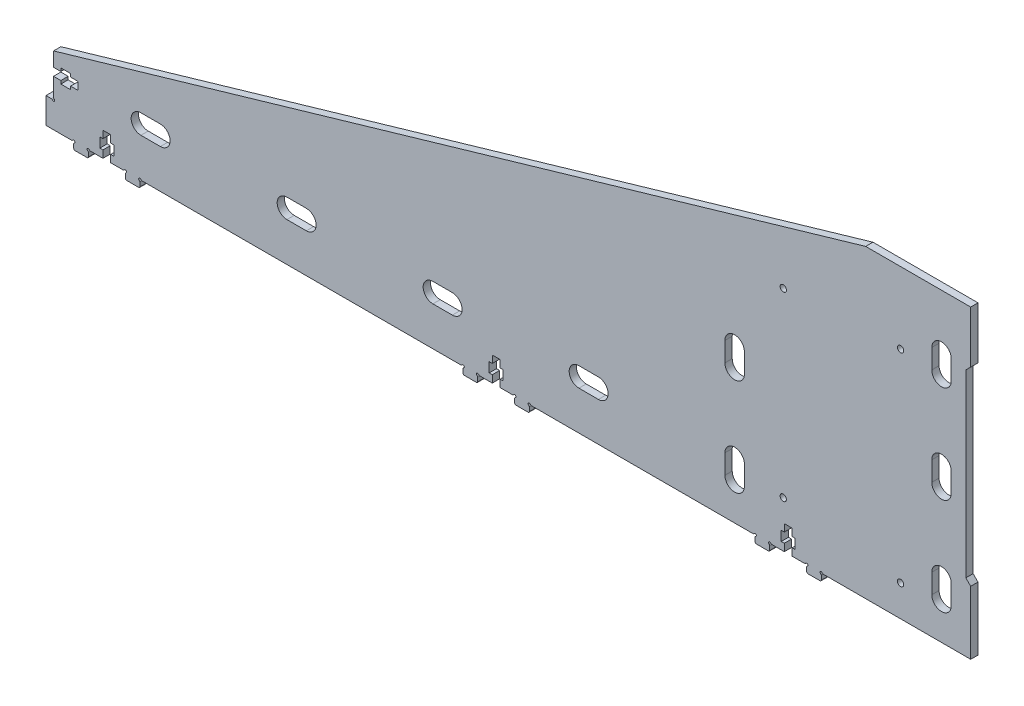
from build123d import *

# Parameters (mm, degrees)
MODEL_R                 = 1.3
SALIENTE_EXTRUIR1_DEPTH = 3


with BuildPart() as part:
    # Model → Saliente-Extruir1 (new body)
    with BuildSketch(Plane.XY):
        with BuildLine():
            Line((387.474128322, 263.996311498), (448.008092322, 263.996308498))
            Line((448.008092322, 263.996308498), (448.008092322, 289.996308498))
            Line((448.008092322, 289.996308498), (446.008092322, 291.996308498))
            Line((446.008092322, 291.996308498), (446.008092322, 365.996306498))
            Line((446.008092322, 365.996306498), (448.008092322, 367.996310498))
            Line((448.008092322, 367.996310498), (448.008092322, 389.371331818))
            Line((448.008092322, 389.371331818), (404.844163308, 389.371331818))
            Line((404.844163308, 389.371331818), (403.197581262, 388.89131343))
            Line((403.197581262, 388.89131343), (81.108137322, 294.994470498))
            Line((81.108137322, 294.994470498), (71.108137322, 292.07922926))
            Line((71.108137322, 292.07922926), (71.108137322, 286.246313498))
            Line((71.108137322, 286.246313498), (74.108109322, 286.246313498))
            Line((74.108109322, 286.246313498), (74.108109322, 287.521307498))
            Line((74.108109322, 287.521307498), (78.108137322, 287.521307498))
            Line((78.108137322, 287.521307498), (78.108137322, 286.246313498))
            Line((78.108137322, 286.246313498), (81.108137322, 286.246313498))
            Line((81.108137322, 286.246313498), (81.108137322, 283.046302498))
            Line((81.108137322, 283.046302498), (78.108137322, 283.046302498))
            Line((78.108137322, 283.046302498), (78.108137322, 281.771307498))
            Line((78.108137322, 281.771307498), (74.108109322, 281.771307498))
            Line((74.108109322, 281.771307498), (74.108109322, 283.046302498))
            Line((74.108109322, 283.046302498), (71.108137322, 283.046302498))
            Line((71.108137322, 283.046302498), (71.108140322, 275.512331498))
            ThreePointArc((71.108140322, 275.512331498), (71.175127106, 275.26233206), (71.358138826, 275.079319332))
            ThreePointArc((71.358138826, 275.079319332), (71.461690809, 274.292753249), (70.675125024, 274.396307498))
            ThreePointArc((70.675125024, 274.396307498), (70.492112322, 274.5793202), (70.242112322, 274.646307498))
            Line((70.242112322, 274.646307498), (68.008065322, 274.646307498))
            Line((68.008065322, 274.646307498), (68.008065322, 263.996308498))
            Line((68.008065322, 263.996308498), (78.542065322, 263.996308498))
            ThreePointArc((78.542065322, 263.996308498), (78.79206566, 264.063295647), (78.97507862, 264.246308498))
            ThreePointArc((78.97507862, 264.246308498), (79.7616439, 264.349861925), (79.658092826, 263.563296336))
            ThreePointArc((79.658092826, 263.563296336), (79.475081188, 263.38028375), (79.408094322, 263.130284498))
            Line((79.408094322, 263.130284498), (79.408094322, 261.496256498))
            ThreePointArc((79.408094322, 261.496256498), (79.554540932, 261.142703108), (79.908094322, 260.996256498))
            Line((79.908094322, 260.996256498), (84.908091322, 260.996256498))
            ThreePointArc((84.908091322, 260.996256498), (85.261644713, 261.142703108), (85.408091322, 261.496256498))
            Line((85.408091322, 261.496256498), (85.408088322, 263.130282498))
            ThreePointArc((85.408088322, 263.130282498), (85.341101173, 263.380282836), (85.158088322, 263.563295796))
            ThreePointArc((85.158088322, 263.563295796), (85.054534895, 264.349861076), (85.841100484, 264.246310002))
            ThreePointArc((85.841100484, 264.246310002), (86.02411307, 264.063298364), (86.274112322, 263.996311498))
            Line((86.274112322, 263.996311498), (91.408077322, 263.996308498))
            Line((91.408077322, 263.996308498), (91.408077322, 266.996280498))
            Line((91.408077322, 266.996280498), (90.133082322, 266.996280498))
            Line((90.133082322, 266.996280498), (90.133082322, 270.996308498))
            Line((90.133082322, 270.996308498), (91.408077322, 270.996308498))
            Line((91.408077322, 270.996308498), (91.408077322, 273.996308498))
            Line((91.408077322, 273.996308498), (94.608088322, 273.996308498))
            Line((94.608088322, 273.996308498), (94.608088322, 270.996308498))
            Line((94.608088322, 270.996308498), (95.883082322, 270.996308498))
            Line((95.883082322, 270.996308498), (95.883082322, 266.996280498))
            Line((95.883082322, 266.996280498), (94.608088322, 266.996280498))
            Line((94.608088322, 266.996280498), (94.608088322, 263.996308498))
            Line((94.608088322, 263.996308498), (99.742082322, 263.996308498))
            ThreePointArc((99.742082322, 263.996308498), (99.992082093, 264.063295897), (100.17509462, 264.246308498))
            ThreePointArc((100.17509462, 264.246308498), (100.9616599, 264.349861925), (100.858108826, 263.563296336))
            ThreePointArc((100.858108826, 263.563296336), (100.675097188, 263.38028375), (100.608110322, 263.130284498))
            Line((100.608110322, 263.130284498), (100.608110322, 261.496256498))
            ThreePointArc((100.608110322, 261.496256498), (100.754556932, 261.142703108), (101.108110322, 260.996256498))
            Line((101.108110322, 260.996256498), (106.108107322, 260.996256498))
            ThreePointArc((106.108107322, 260.996256498), (106.461660713, 261.142703108), (106.608107322, 261.496256498))
            Line((106.608107322, 261.496256498), (106.608104322, 263.130282498))
            ThreePointArc((106.608104322, 263.130282498), (106.541117173, 263.380282836), (106.358104322, 263.563295796))
            ThreePointArc((106.358104322, 263.563295796), (106.254550895, 264.349861076), (107.041116484, 264.246310002))
            ThreePointArc((107.041116484, 264.246310002), (107.22412907, 264.063298364), (107.474128322, 263.996311498))
            Line((107.474128322, 263.996311498), (238.540330274, 263.996311498))
            Line((238.540330274, 263.996311498), (238.542062322, 263.996311498))
            ThreePointArc((238.542062322, 263.996311498), (238.792061575, 264.063297598), (238.97507462, 264.246308498))
            ThreePointArc((238.97507462, 264.246308498), (239.7616399, 264.349861925), (239.658088826, 263.563296336))
            ThreePointArc((239.658088826, 263.563296336), (239.475077188, 263.38028375), (239.408090322, 263.130284498))
            Line((239.408090322, 263.130284498), (239.408090322, 261.496256498))
            ThreePointArc((239.408090322, 261.496256498), (239.554536932, 261.142703108), (239.908090322, 260.996256498))
            Line((239.908090322, 260.996256498), (244.908088322, 260.996256498))
            ThreePointArc((244.908088322, 260.996256498), (245.261641713, 261.142703108), (245.408088322, 261.496256498))
            Line((245.408088322, 261.496256498), (245.408085322, 263.130282498))
            ThreePointArc((245.408085322, 263.130282498), (245.341098173, 263.380282836), (245.158085322, 263.563295796))
            ThreePointArc((245.158085322, 263.563295796), (245.054530136, 264.349861683), (245.841096484, 264.246310002))
            ThreePointArc((245.841096484, 264.246310002), (246.02410907, 264.063298364), (246.274108322, 263.996311498))
            Line((246.274108322, 263.996311498), (251.408073322, 263.996308498))
            Line((251.408073322, 263.996308498), (251.408073322, 266.996280498))
            Line((251.408073322, 266.996280498), (250.133079322, 266.996280498))
            Line((250.133079322, 266.996280498), (250.133079322, 270.996308498))
            Line((250.133079322, 270.996308498), (251.408073322, 270.996308498))
            Line((251.408073322, 270.996308498), (251.408073322, 273.996308498))
            Line((251.408073322, 273.996308498), (254.608084322, 273.996308498))
            Line((254.608084322, 273.996308498), (254.608084322, 270.996308498))
            Line((254.608084322, 270.996308498), (255.883079322, 270.996308498))
            Line((255.883079322, 270.996308498), (255.883079322, 266.996280498))
            Line((255.883079322, 266.996280498), (254.608084322, 266.996280498))
            Line((254.608084322, 266.996280498), (254.608084322, 263.996308498))
            Line((254.608084322, 263.996308498), (259.742078322, 263.996308498))
            ThreePointArc((259.742078322, 263.996308498), (259.992078093, 264.063295897), (260.17509062, 264.246308498))
            ThreePointArc((260.17509062, 264.246308498), (260.9616559, 264.349861925), (260.858104826, 263.563296336))
            ThreePointArc((260.858104826, 263.563296336), (260.675093188, 263.38028375), (260.608106322, 263.130284498))
            Line((260.608106322, 263.130284498), (260.608106322, 261.496256498))
            ThreePointArc((260.608106322, 261.496256498), (260.754552932, 261.142703108), (261.108106322, 260.996256498))
            Line((261.108106322, 260.996256498), (266.108104322, 260.996256498))
            ThreePointArc((266.108104322, 260.996256498), (266.461657713, 261.142703108), (266.608104322, 261.496256498))
            Line((266.608104322, 261.496256498), (266.608101322, 263.130282498))
            ThreePointArc((266.608101322, 263.130282498), (266.541114173, 263.380282836), (266.358101322, 263.563295796))
            ThreePointArc((266.358101322, 263.563295796), (266.254546136, 264.349861683), (267.041112484, 264.246310002))
            ThreePointArc((267.041112484, 264.246310002), (267.22412507, 264.063298364), (267.474124322, 263.996311498))
            Line((267.474124322, 263.996311498), (358.540334274, 263.996311498))
            Line((358.540334274, 263.996311498), (358.542066322, 263.996308498))
            ThreePointArc((358.542066322, 263.996308498), (358.792066093, 264.063295897), (358.97507862, 264.246308498))
            ThreePointArc((358.97507862, 264.246308498), (359.7616439, 264.349861925), (359.658092826, 263.563296336))
            ThreePointArc((359.658092826, 263.563296336), (359.475081188, 263.38028375), (359.408094322, 263.130284498))
            Line((359.408094322, 263.130284498), (359.408094322, 261.496256498))
            ThreePointArc((359.408094322, 261.496256498), (359.554540932, 261.142703108), (359.908094322, 260.996256498))
            Line((359.908094322, 260.996256498), (364.908091322, 260.996256498))
            ThreePointArc((364.908091322, 260.996256498), (365.261644713, 261.142703108), (365.408091322, 261.496256498))
            Line((365.408091322, 261.496256498), (365.408088322, 263.130282498))
            ThreePointArc((365.408088322, 263.130282498), (365.341101173, 263.380282836), (365.158088322, 263.563295796))
            ThreePointArc((365.158088322, 263.563295796), (365.054534895, 264.349861076), (365.841100484, 264.246310002))
            ThreePointArc((365.841100484, 264.246310002), (366.02411307, 264.063298364), (366.274112322, 263.996311498))
            Line((366.274112322, 263.996311498), (371.408077322, 263.996308498))
            Line((371.408077322, 263.996308498), (371.408077322, 266.996280498))
            Line((371.408077322, 266.996280498), (370.133083322, 266.996280498))
            Line((370.133083322, 266.996280498), (370.133083322, 270.996308498))
            Line((370.133083322, 270.996308498), (371.408077322, 270.996308498))
            Line((371.408077322, 270.996308498), (371.408077322, 273.996308498))
            Line((371.408077322, 273.996308498), (374.608088322, 273.996308498))
            Line((374.608088322, 273.996308498), (374.608088322, 270.996308498))
            Line((374.608088322, 270.996308498), (375.883083322, 270.996308498))
            Line((375.883083322, 270.996308498), (375.883083322, 266.996280498))
            Line((375.883083322, 266.996280498), (374.608088322, 266.996280498))
            Line((374.608088322, 266.996280498), (374.608088322, 263.996308498))
            Line((374.608088322, 263.996308498), (379.742082322, 263.996308498))
            ThreePointArc((379.742082322, 263.996308498), (379.992082093, 264.063295897), (380.17509462, 264.246308498))
            ThreePointArc((380.17509462, 264.246308498), (380.9616599, 264.349861925), (380.858108826, 263.563296336))
            ThreePointArc((380.858108826, 263.563296336), (380.675097188, 263.38028375), (380.608110322, 263.130284498))
            Line((380.608110322, 263.130284498), (380.608110322, 261.496256498))
            ThreePointArc((380.608110322, 261.496256498), (380.754556932, 261.142703108), (381.108110322, 260.996256498))
            Line((381.108110322, 260.996256498), (386.108108322, 260.996256498))
            ThreePointArc((386.108108322, 260.996256498), (386.461661713, 261.142703108), (386.608108322, 261.496256498))
            Line((386.608108322, 261.496256498), (386.608105322, 263.130282498))
            ThreePointArc((386.608105322, 263.130282498), (386.541118173, 263.380282836), (386.358105322, 263.563295796))
            ThreePointArc((386.358105322, 263.563295796), (386.254551321, 264.349861278), (387.04111716, 264.246309995))
            ThreePointArc((387.04111716, 264.246309995), (387.224129455, 264.06329853), (387.474128322, 263.996311498))
        make_face()
        with Locations((419.169547464, 276.784810642)):
            Circle(MODEL_R, mode=Mode.SUBTRACT)
        with Locations((419.190433996, 359.984810147)):
            Circle(MODEL_R, mode=Mode.SUBTRACT)
        with Locations((370.975511179, 283.007806353)):
            Circle(MODEL_R, mode=Mode.SUBTRACT)
        with Locations((370.992246648, 357.507806848)):
            Circle(MODEL_R, mode=Mode.SUBTRACT)
        with BuildLine():
            Line((115.008095322, 287.996309498), (107.008095322, 287.996309498))
            ThreePointArc((107.008095322, 287.996309498), (103.008095322, 283.996309498), (107.008095322, 279.996309498))
            Line((107.008095322, 279.996309498), (115.008095322, 279.996309498))
            ThreePointArc((115.008095322, 279.996309498), (119.008095322, 283.996309498), (115.008095322, 287.996309498))
        make_face(mode=Mode.SUBTRACT)
        with BuildLine():
            Line((175.008095322, 287.996309498), (167.008095322, 287.996309498))
            ThreePointArc((167.008095322, 287.996309498), (163.008095322, 283.996309498), (167.008095322, 279.996309498))
            Line((167.008095322, 279.996309498), (175.008095322, 279.996309498))
            ThreePointArc((175.008095322, 279.996309498), (179.008095322, 283.996309498), (175.008095322, 287.996309498))
        make_face(mode=Mode.SUBTRACT)
        with BuildLine():
            Line((235.008095322, 287.996309498), (227.008095322, 287.996309498))
            ThreePointArc((227.008095322, 287.996309498), (223.008095322, 283.996309498), (227.008095322, 279.996309498))
            Line((227.008095322, 279.996309498), (235.008095322, 279.996309498))
            ThreePointArc((235.008095322, 279.996309498), (239.008095322, 283.996309498), (235.008095322, 287.996309498))
        make_face(mode=Mode.SUBTRACT)
        with BuildLine():
            Line((295.008095322, 287.996309498), (287.008095322, 287.996309498))
            ThreePointArc((287.008095322, 287.996309498), (283.008095322, 283.996309498), (287.008095322, 279.996309498))
            Line((287.008095322, 279.996309498), (295.008095322, 279.996309498))
            ThreePointArc((295.008095322, 279.996309498), (299.008095322, 283.996309498), (295.008095322, 287.996309498))
        make_face(mode=Mode.SUBTRACT)
        with BuildLine():
            Line((355.008092322, 278.996307498), (355.008092322, 286.996308498))
            ThreePointArc((355.008092322, 286.996308498), (351.008092322, 290.996308498), (347.008092322, 286.996308498))
            Line((347.008092322, 286.996308498), (347.008092322, 278.996307498))
            ThreePointArc((347.008092322, 278.996307498), (351.008092322, 274.996307498), (355.008092322, 278.996307498))
        make_face(mode=Mode.SUBTRACT)
        with BuildLine():
            Line((355.008092322, 318.996307498), (355.008092322, 326.996308498))
            ThreePointArc((355.008092322, 326.996308498), (351.008092322, 330.996308498), (347.008092322, 326.996308498))
            Line((347.008092322, 326.996308498), (347.008092322, 318.996307498))
            ThreePointArc((347.008092322, 318.996307498), (351.008092322, 314.996307498), (355.008092322, 318.996307498))
        make_face(mode=Mode.SUBTRACT)
        with BuildLine():
            Line((440.008092322, 318.996307498), (440.008092322, 326.996308498))
            ThreePointArc((440.008092322, 326.996308498), (436.008092322, 330.996308498), (432.008092322, 326.996308498))
            Line((432.008092322, 326.996308498), (432.008092322, 318.996307498))
            ThreePointArc((432.008092322, 318.996307498), (436.008092322, 314.996307498), (440.008092322, 318.996307498))
        make_face(mode=Mode.SUBTRACT)
        with BuildLine():
            Line((440.008092322, 358.996307498), (440.008092322, 366.996308498))
            ThreePointArc((440.008092322, 366.996308498), (436.008092322, 370.996308498), (432.008092322, 366.996308498))
            Line((432.008092322, 366.996308498), (432.008092322, 358.996307498))
            ThreePointArc((432.008092322, 358.996307498), (436.008092322, 354.996307498), (440.008092322, 358.996307498))
        make_face(mode=Mode.SUBTRACT)
        with BuildLine():
            Line((440.008092322, 278.996308149), (440.008092322, 286.996308498))
            ThreePointArc((440.008092322, 286.996308498), (436.008092322, 290.996308498), (432.008092322, 286.996308498))
            Line((432.008092322, 286.996308498), (432.008092322, 278.996307498))
            ThreePointArc((432.008092322, 278.996307498), (436.008092648, 274.996307824), (440.008092322, 278.996308149))
        make_face(mode=Mode.SUBTRACT)
    extrude(amount=SALIENTE_EXTRUIR1_DEPTH)


solid = part.part
